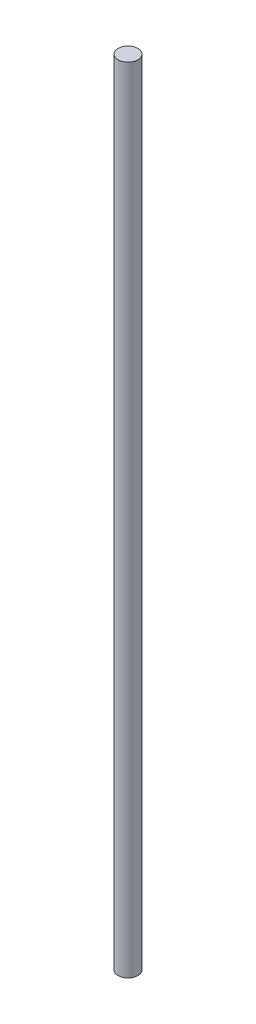
from build123d import *

# Parameters (mm, degrees)
SKETCH1_R           = 3.175
BOSS_EXTRUDE1_DEPTH = 254


with BuildPart() as part:
    # Sketch1 → Boss-Extrude1 (new body)
    with BuildSketch(Plane(origin=(0, 0, 0), x_dir=(1, 0, 0), z_dir=(0, 1, 0))):
        Circle(SKETCH1_R)
    extrude(amount=BOSS_EXTRUDE1_DEPTH)


solid = part.part
